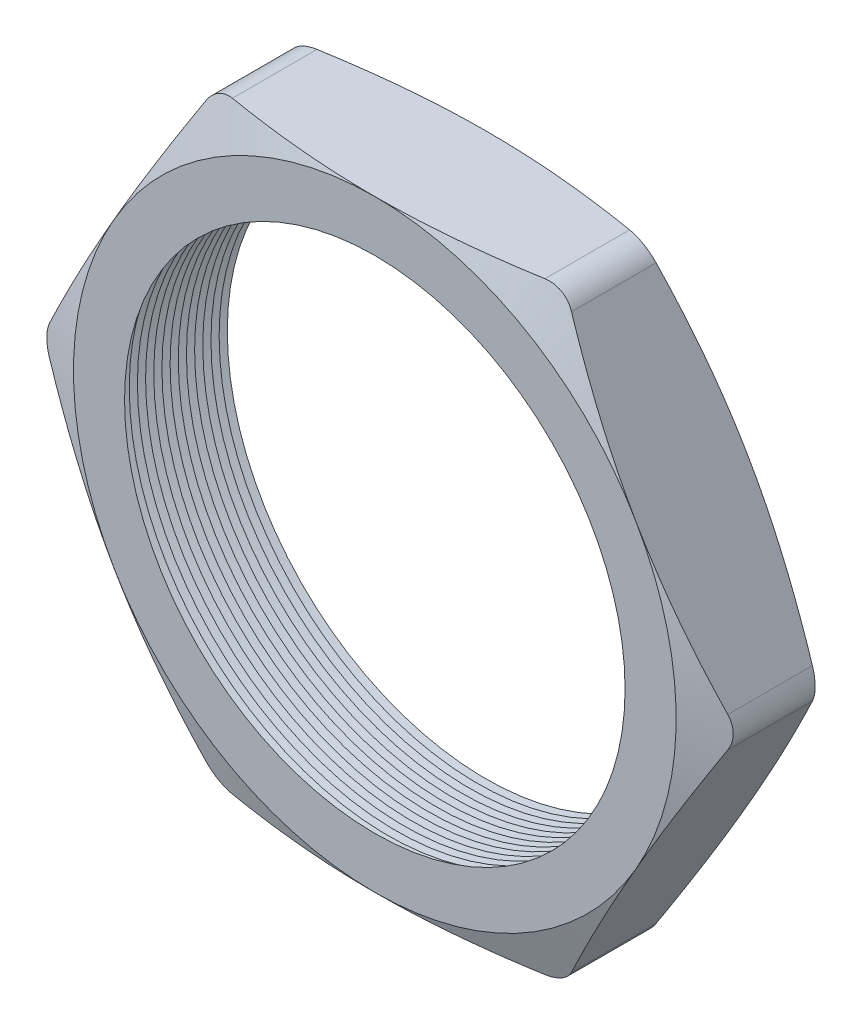
from build123d import *

# Parameters (mm, degrees)
SKETCH1_R          = 6.223
EXTRUDE1_DEPTH     = 2.794
FILLET1_R          = 0.762
SKETCH2_OUTSIDE_W  = 44.492
SKETCH2_OUTSIDE_H  = 42.41
SKETCH2_OUTSIDE_R  = 7.493
CUT_EXTRUDE1_DEPTH = 3.794
CUT_EXTRUDE1_DRAFT = -70
SKETCH3_OUTSIDE_W  = 44.492
SKETCH3_OUTSIDE_H  = 42.41
SKETCH3_OUTSIDE_R  = 7.493
CUT_EXTRUDE2_DEPTH = 3.7940001
CUT_EXTRUDE2_DRAFT = -70
LPATTERN1_COUNT    = 14
LPATTERN1_PITCH    = 0.2032


with BuildPart() as part:
    # Sketch1 → Extrude1 (new body)
    with BuildSketch(Plane.XY):
        Polygon((-8.652171134, 0), (-4.326085567, -7.493), (4.326085567, -7.493), (8.652171134, 0), (4.326085567, 7.493), (-4.326085567, 7.493), align=None)
        Circle(SKETCH1_R, mode=Mode.SUBTRACT)
    extrude(amount=EXTRUDE1_DEPTH)

    # Fillet1
    fillet1_edges = [part.edges().sort_by_distance(p)[0] for p in [
        (8.652171134, 0, 1.397),
        (4.326085567, -7.493, 1.397),
        (-4.326085567, -7.493, 1.397),
        (-8.652171134, 0, 1.397),
        (-4.326085567, 7.493, 1.397),
        (4.326085567, 7.493, 1.397),
    ]]
    fillet(fillet1_edges, radius=FILLET1_R)


with BuildPart() as cut_extrude1_tool:
    # Sketch2 outside → Cut-Extrude1 (with draft: the straight prism first)
    with BuildSketch(Plane.XY.offset(2.794)):
        Rectangle(SKETCH2_OUTSIDE_W, SKETCH2_OUTSIDE_H)
        Circle(SKETCH2_OUTSIDE_R, mode=Mode.SUBTRACT)
    extrude(amount=-CUT_EXTRUDE1_DEPTH)
    # Cut-Extrude1: the draft: its side faces are tilted about the plane it starts from
    cut_extrude1_sides = [cut_extrude1_tool.faces().sort_by_distance(p)[0] for p in [
        (0, -21.205, 0.897),
        (22.246, 0, 0.897),
        (0, 21.205, 0.897),
        (-22.246, 0, 0.897),
        (-7.493, 0, 0.897),
    ]]
    draft(cut_extrude1_sides, Plane.XY.offset(2.794), CUT_EXTRUDE1_DRAFT)


with BuildPart() as part_1:
    add(part.part)

    # Cut-Extrude1: cut by cut_extrude1_tool
    add(cut_extrude1_tool.part, mode=Mode.SUBTRACT)


with BuildPart() as cut_extrude2_tool:
    # Sketch3 outside → Cut-Extrude2 (with draft: the straight prism first)
    with BuildSketch(Plane(origin=(0, 0, 0), x_dir=(-1, 0, 0), z_dir=(0, 0, -1))):
        Rectangle(SKETCH3_OUTSIDE_W, SKETCH3_OUTSIDE_H)
        Circle(SKETCH3_OUTSIDE_R, mode=Mode.SUBTRACT)
    extrude(amount=-CUT_EXTRUDE2_DEPTH)
    # Cut-Extrude2: the draft: its side faces are tilted about the plane it starts from
    cut_extrude2_sides = [cut_extrude2_tool.faces().sort_by_distance(p)[0] for p in [
        (0, -21.205, 1.89700005),
        (-22.246, 0, 1.89700005),
        (0, 21.205, 1.89700005),
        (22.246, 0, 1.89700005),
        (7.493, 0, 1.89700005),
    ]]
    draft(cut_extrude2_sides, Plane(origin=(0, 0, 0), x_dir=(-1, 0, 0), z_dir=(0, 0, -1)), CUT_EXTRUDE2_DRAFT)


with BuildPart() as part_2:
    add(part_1.part)

    # Cut-Extrude2: cut by cut_extrude2_tool
    add(cut_extrude2_tool.part, mode=Mode.SUBTRACT)

    # Sketch4 → Cut-Revolve1 (revolve, cut)
    with BuildSketch(Plane(origin=(0, 0, 0), x_dir=(1, 0, 0), z_dir=(0, 1, 0))):
        Polygon((-6.223, -2.794), (-6.223, -2.354059095), (-6.604, -2.574029547), align=None)
    cut_revolve1 = revolve(axis=Axis((0, 0, 2.794), (0, 0, -1)), mode=Mode.SUBTRACT)

    # LPattern1: Cut-Revolve1 ×14
    with Locations(*[(0, 0, -i * LPATTERN1_PITCH) for i in range(1, LPATTERN1_COUNT)]):
        add(cut_revolve1, mode=Mode.SUBTRACT)


solid = part_2.part
